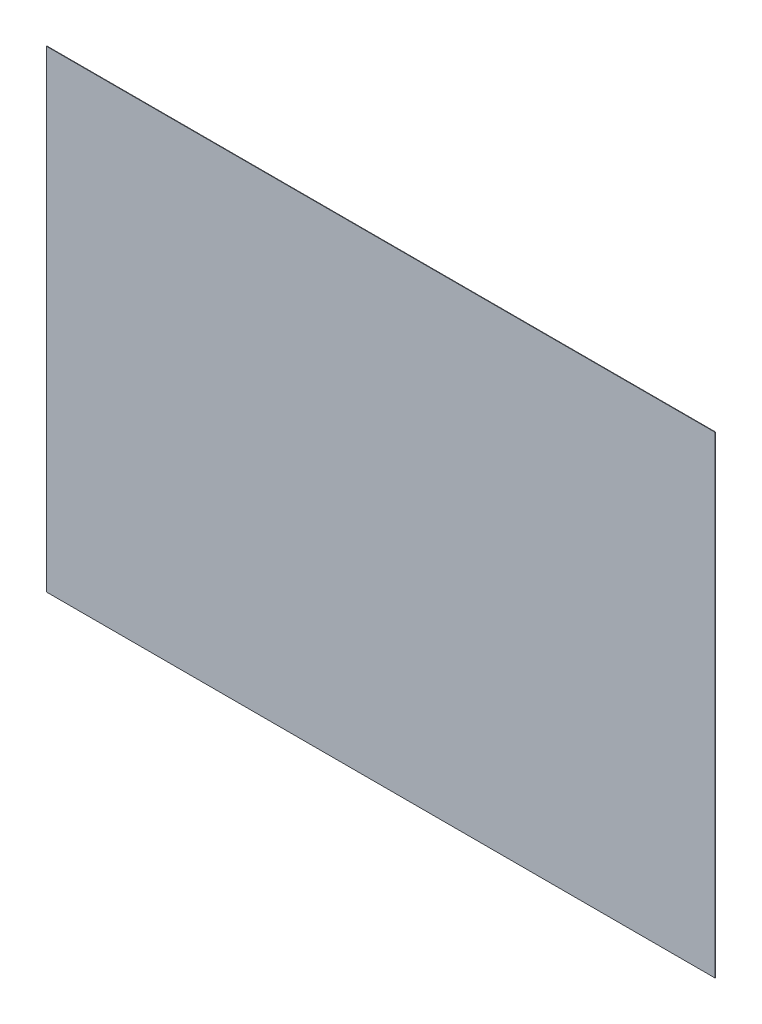
from build123d import *

# Parameters (mm, degrees)
SKETCH1_W           = 420
SKETCH1_H           = 297
BOSS_EXTRUDE1_DEPTH = 0.3


with BuildPart() as part:
    # Sketch1 → Boss-Extrude1 (new body)
    with BuildSketch(Plane.XY):
        Rectangle(SKETCH1_W, SKETCH1_H)
    extrude(amount=BOSS_EXTRUDE1_DEPTH)


solid = part.part
